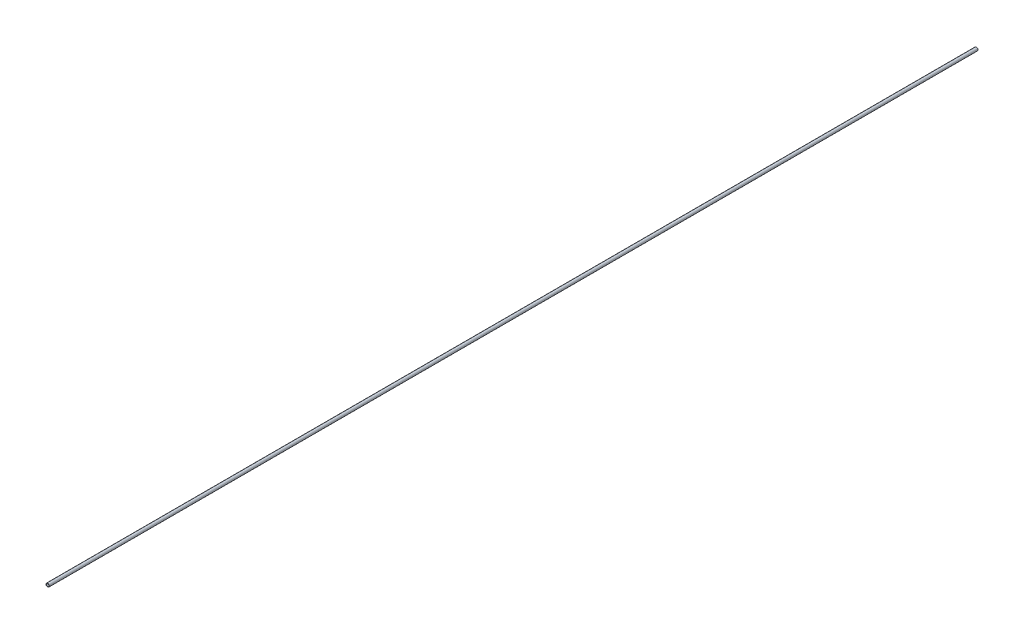
from build123d import *

# Parameters (mm, degrees)
SKETCH1_R           = 10.668
SKETCH1_R_2         = 7.8994
EXTRUDE_THIN1_DEPTH = 3000


with BuildPart() as part:
    # Sketch1 → Extrude-Thin1 (new body, symmetric)
    with BuildSketch(Plane.XY):
        Circle(SKETCH1_R)
        Circle(SKETCH1_R_2, mode=Mode.SUBTRACT)
    extrude(amount=EXTRUDE_THIN1_DEPTH, both=True)


solid = part.part
